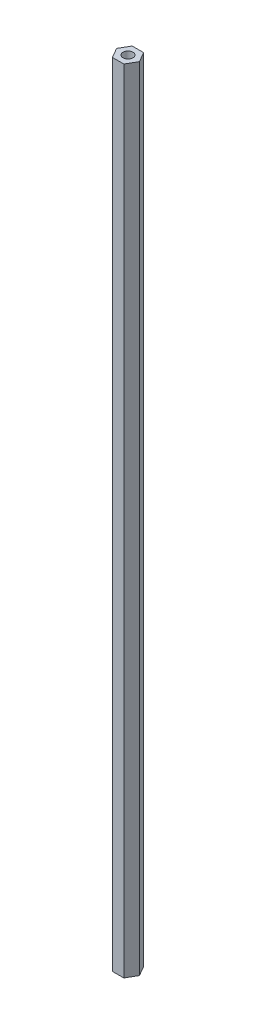
from build123d import *

# Parameters (mm, degrees)
SKETCH1_R           = 3.175
BOSS_EXTRUDE1_DEPTH = 508


with BuildPart() as part:
    # Sketch1 → Boss-Extrude1 (new body)
    with BuildSketch(Plane(origin=(0, 0, 0), x_dir=(1, 0, 0), z_dir=(0, 1, 0))):
        Polygon((3.666174209, -6.35), (7.332348419, 0), (3.666174209, 6.35), (-3.666174209, 6.35), (-7.332348419, 0), (-3.666174209, -6.35), align=None)
        Circle(SKETCH1_R, mode=Mode.SUBTRACT)
    extrude(amount=BOSS_EXTRUDE1_DEPTH)


solid = part.part
